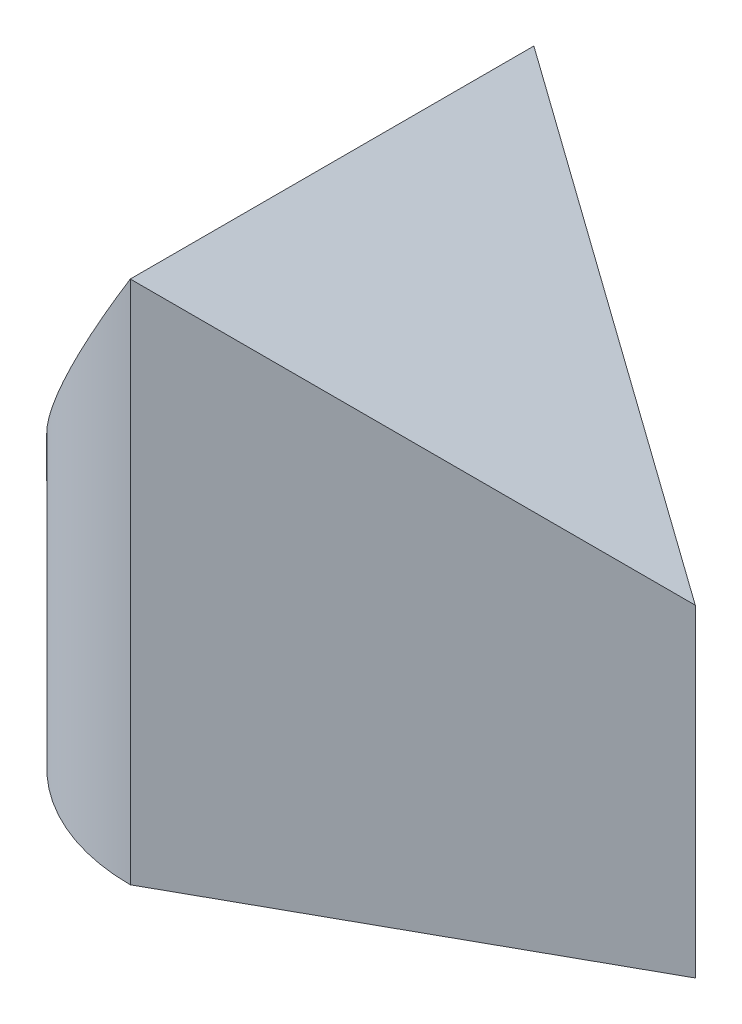
from build123d import *

# Parameters (mm, degrees)
EXTRUDE1_DEPTH     = 65
CUT_EXTRUDE1_DEPTH = 25


with BuildPart() as part:
    # Sketch1 → Extrude1 (new body)
    with BuildSketch(Plane(origin=(0, 0, 0), x_dir=(1, 0, 0), z_dir=(0, 1, 0))):
        with BuildLine():
            Line((0, 25), (45, 0))
            Line((45, 0), (0, -25))
            ThreePointArc((0, -25), (-25, 0), (0, 25))
        make_face()
    extrude(amount=EXTRUDE1_DEPTH)

    # Sketch2 → Cut-Extrude1 (cut, symmetric)
    with BuildSketch(Plane.XY):
        Polygon((45, 65), (0, 65), (45, 40), align=None)
        Polygon((-25, 24), (0, 65), (-25, 65), align=None)
    extrude(amount=CUT_EXTRUDE1_DEPTH, both=True, mode=Mode.SUBTRACT)


solid = part.part
